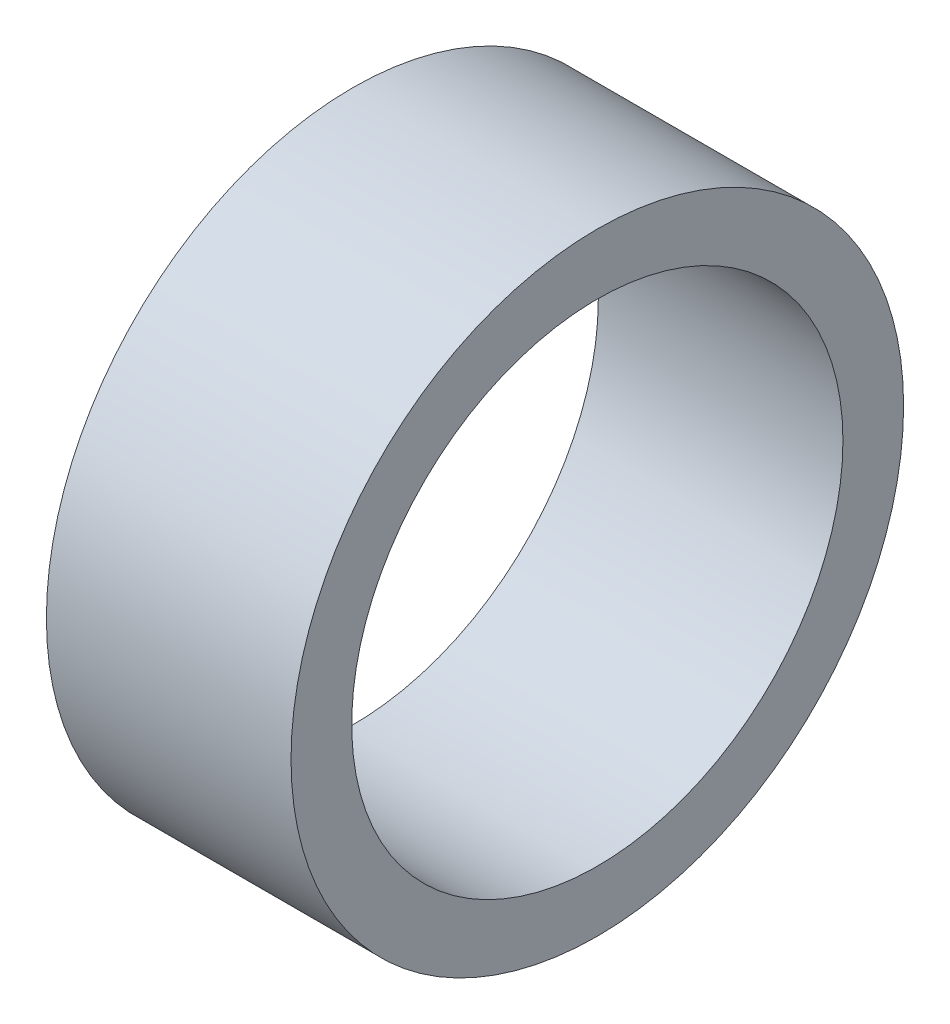
from build123d import *

# Parameters (mm, degrees)
SKETCH1_R           = 3.9751
SKETCH1_R_2         = 3.1877
BOSS_EXTRUDE1_DEPTH = 1.5875


with BuildPart() as part:
    # Sketch1 → Boss-Extrude1 (new body, symmetric)
    with BuildSketch(Plane(origin=(0, 0, 0), x_dir=(0, 0, -1), z_dir=(1, 0, 0))):
        Circle(SKETCH1_R)
        Circle(SKETCH1_R_2, mode=Mode.SUBTRACT)
    extrude(amount=BOSS_EXTRUDE1_DEPTH, both=True)


solid = part.part
